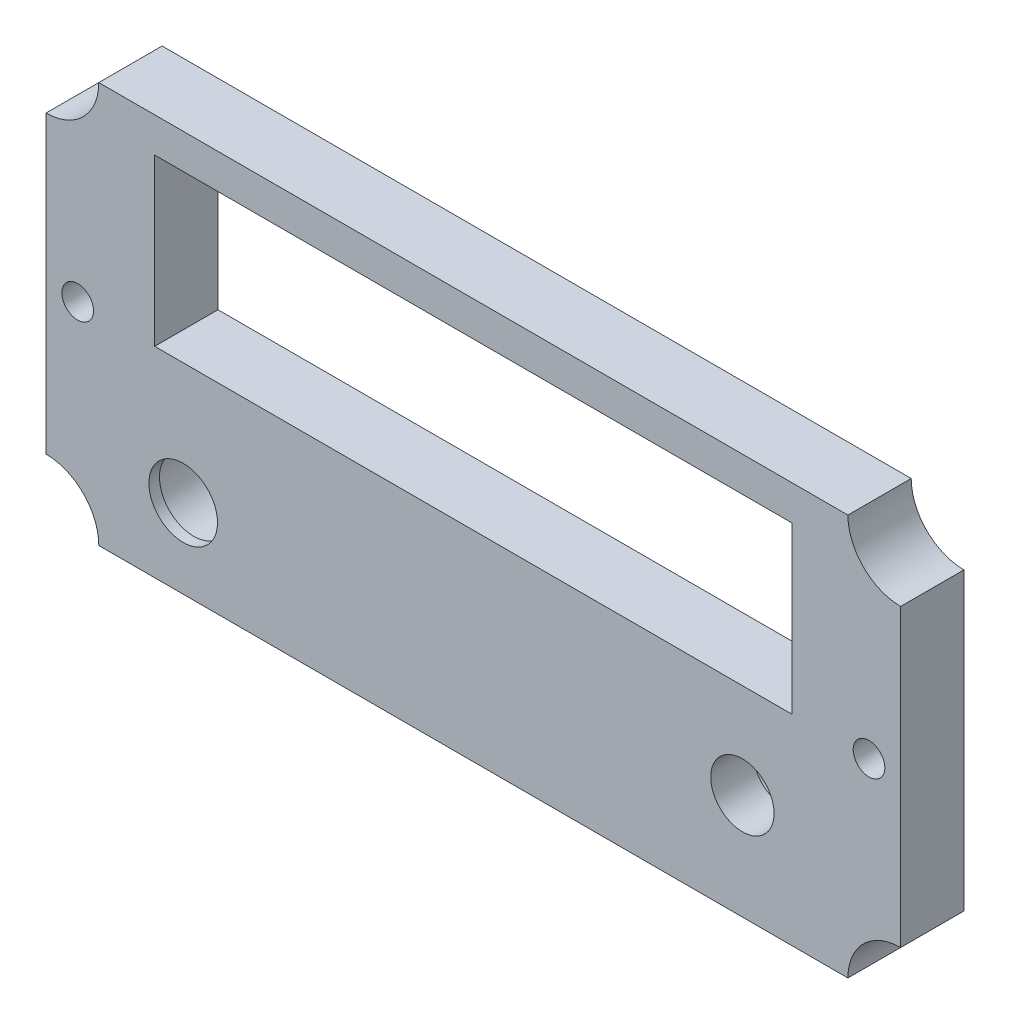
from build123d import *

# Parameters (mm, degrees)
BASE_DEPTH                        = 6
SKETCH2_R                         = 1.5
SCREWS_CUT_DEPTH                  = 1
SCREWS_CUT_DEPTH_BACK             = 7
SKETCH4_W                         = 60.4
SKETCH4_H                         = 15.7
LCD_CUT_DEPTH                     = 1
LCD_CUT_DEPTH_BACK                = 7
SKETCH5_R                         = 3.75
TESTBUTTON_BIG_CUT_DEPTH          = 1
TESTBUTTON_BIG_CUT_DEPTH_BACK     = 7
SKETCH6_R                         = 4
SKETCH6_R_2                       = 3.25
TESTBUTTON_PIECE_MAINTAINER_DEPTH = 1
SKETCH7_R                         = 3.425
BRIGHTNESS_CUT_DEPTH              = 1
BRIGHTNESS_CUT_DEPTH_BACK         = 7
SKETCH8_R                         = 3.5
SKETCH8_R_2                       = 3
BRIGHTNESS_BACK_CUT_DEPTH         = 4


with BuildPart() as part:
    # Sketch1 → Base (new body)
    with BuildSketch(Plane.XY):
        with BuildLine():
            Line((-35.5, 19), (35.5, 19))
            ThreePointArc((35.5, 19), (36.964466094, 15.464466094), (40.5, 14))
            Line((40.5, 14), (40.5, -14))
            ThreePointArc((40.5, -14), (36.964466094, -15.464466094), (35.5, -19))
            Line((35.5, -19), (-35.5, -19))
            ThreePointArc((-35.5, -19), (-36.964466094, -15.464466094), (-40.5, -14))
            Line((-40.5, -14), (-40.5, 14))
            ThreePointArc((-40.5, 14), (-36.964466094, 15.464466094), (-35.5, 19))
        make_face()
    extrude(amount=BASE_DEPTH)

    # Sketch2 → Screws Cut (cut, two sides)
    with BuildSketch(Plane.XY.offset(6)) as screws_cut_sk:
        with Locations((-37.5, 0)):
            Circle(SKETCH2_R)
        with Locations((37.5, 0)):
            Circle(SKETCH2_R)
    extrude(amount=SCREWS_CUT_DEPTH, mode=Mode.SUBTRACT)
    extrude(screws_cut_sk.sketch, amount=-SCREWS_CUT_DEPTH_BACK, mode=Mode.SUBTRACT)

    # Sketch4 → LCD Cut (cut, two sides)
    with BuildSketch(Plane.XY.offset(6)) as lcd_cut_sk:
        with Locations((0, 7.85)):
            Rectangle(SKETCH4_W, SKETCH4_H)
    extrude(amount=LCD_CUT_DEPTH, mode=Mode.SUBTRACT)
    extrude(lcd_cut_sk.sketch, amount=-LCD_CUT_DEPTH_BACK, mode=Mode.SUBTRACT)

    # Sketch5 → TestButton Big Cut (cut, two sides)
    with BuildSketch(Plane.XY.offset(6)) as testbutton_big_cut_sk:
        with Locations((-27.5, -11.5)):
            Circle(SKETCH5_R)
    extrude(amount=TESTBUTTON_BIG_CUT_DEPTH, mode=Mode.SUBTRACT)
    extrude(testbutton_big_cut_sk.sketch, amount=-TESTBUTTON_BIG_CUT_DEPTH_BACK, mode=Mode.SUBTRACT)

    # Sketch6 → TestButton Piece Maintainer (add)
    with BuildSketch(Plane.XY.offset(6)):
        with Locations((-27.5, -11.5)):
            Circle(SKETCH6_R)
        with Locations((-27.5, -11.5)):
            Circle(SKETCH6_R_2, mode=Mode.SUBTRACT)
    extrude(amount=-TESTBUTTON_PIECE_MAINTAINER_DEPTH)

    # Sketch7 → Brightness Cut (cut, two sides)
    with BuildSketch(Plane.XY.offset(6)) as brightness_cut_sk:
        with Locations((25.5, -9)):
            Circle(SKETCH7_R)
    extrude(amount=BRIGHTNESS_CUT_DEPTH, mode=Mode.SUBTRACT)
    extrude(brightness_cut_sk.sketch, amount=-BRIGHTNESS_CUT_DEPTH_BACK, mode=Mode.SUBTRACT)

    # Sketch8 → Brightness Back Cut (add)
    with BuildSketch(Plane.XY.offset(6)):
        with Locations((25.5, -9)):
            Circle(SKETCH8_R)
        with Locations((25.5, -9)):
            Circle(SKETCH8_R_2, mode=Mode.SUBTRACT)
    extrude(amount=-BRIGHTNESS_BACK_CUT_DEPTH)


solid = part.part
